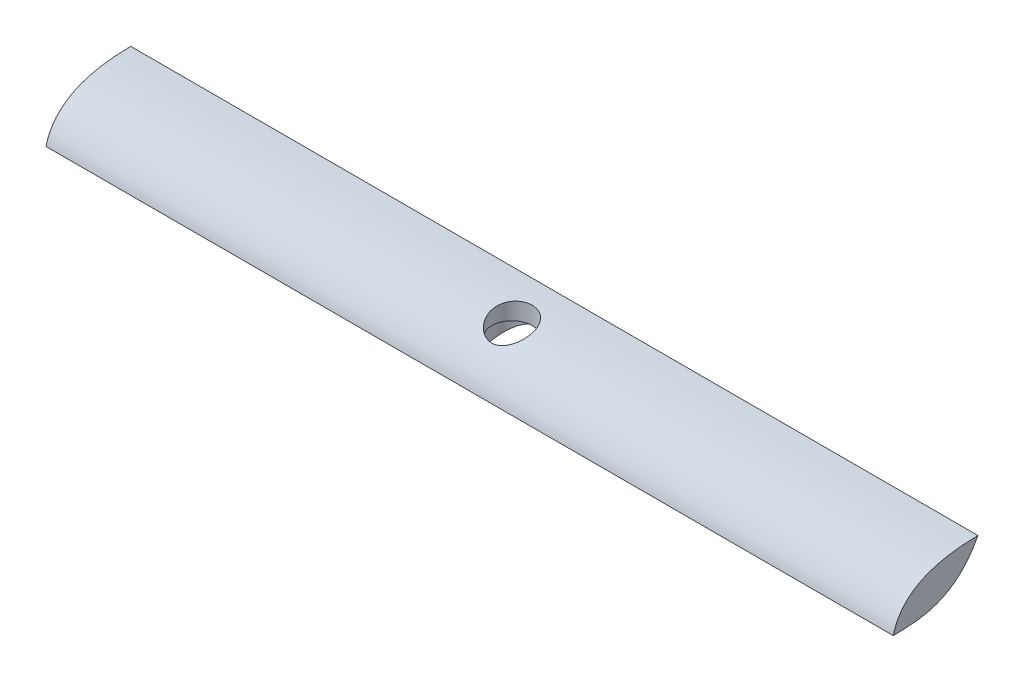
from build123d import *

# Parameters (mm, degrees)
ESQUISSE1_R             = 6
BOSS_EXTRU_1_DEPTH      = 6.8
ESQUISSE4_W             = 130
ESQUISSE4_H             = 13
BOSS_EXTRU_4_DEPTH      = 6.8
ESQUISSE2_R             = 3.1
ENL_V_MAT_EXTRU_1_DEPTH = 3.9
ESQUISSE3_R             = 4
ENL_V_MAT_EXTRU_2_DEPTH = 3.9
ENL_V_MAT_EXTRU_3_DEPTH = 150


with BuildPart() as part:
    # Esquisse1 → Boss.-Extru.1 (new body)
    with BuildSketch(Plane(origin=(0, 0, 0), x_dir=(1, 0, 0), z_dir=(0, 1, 0))):
        Circle(ESQUISSE1_R)
    extrude(amount=BOSS_EXTRU_1_DEPTH)

    # Esquisse4 → Boss.-Extru.4 (add)
    with BuildSketch(Plane(origin=(0, 6.8, 0), x_dir=(-1, 0, 0), z_dir=(0, 1, 0))):
        Rectangle(ESQUISSE4_W, ESQUISSE4_H)
    extrude(amount=-BOSS_EXTRU_4_DEPTH)

    # Esquisse2 → Enlèv. mat.-Extru.1 (cut)
    with BuildSketch(Plane(origin=(0, 6.8, 0), x_dir=(-1, 0, 0), z_dir=(0, 1, 0))):
        Circle(ESQUISSE2_R)
    extrude(amount=-ENL_V_MAT_EXTRU_1_DEPTH, mode=Mode.SUBTRACT)

    # Esquisse3 → Enlèv. mat.-Extru.2 (cut)
    with BuildSketch(Plane.XZ):
        Circle(ESQUISSE3_R)
    extrude(amount=-ENL_V_MAT_EXTRU_2_DEPTH, mode=Mode.SUBTRACT)

    # Esquisse5 → Enlèv. mat.-Extru.3 (cut)
    with BuildSketch(Plane.ZY.offset(65)):
        with BuildLine():
            add(Edge.make_bspline(
                [(-6.5, 6.8), (-3.157180199, 0.502662842), (1.616492489, 0.027857453), (6.5, 0)],
                knots=[0, 0, 0, 0, 0.886960636, 0.886960636, 0.886960636, 0.886960636], degree=3))
            Line((-6.5, 6.8), (-6.5, 0))
            Line((-6.5, 0), (6.5, 0))
        make_face()
        with BuildLine():
            Line((6.5, 6.8), (-6.5, 6.8))
            add(Edge.make_bspline(
                [(-6.5, 6.8), (4.798338337, 6.746141113), (6.5, 0)],
                knots=[0, 0, 0, 0.863622033, 0.863622033, 0.863622033], degree=2))
            Line((6.5, 0), (6.5, 6.8))
        make_face()
    extrude(amount=-ENL_V_MAT_EXTRU_3_DEPTH, mode=Mode.SUBTRACT)


solid = part.part
